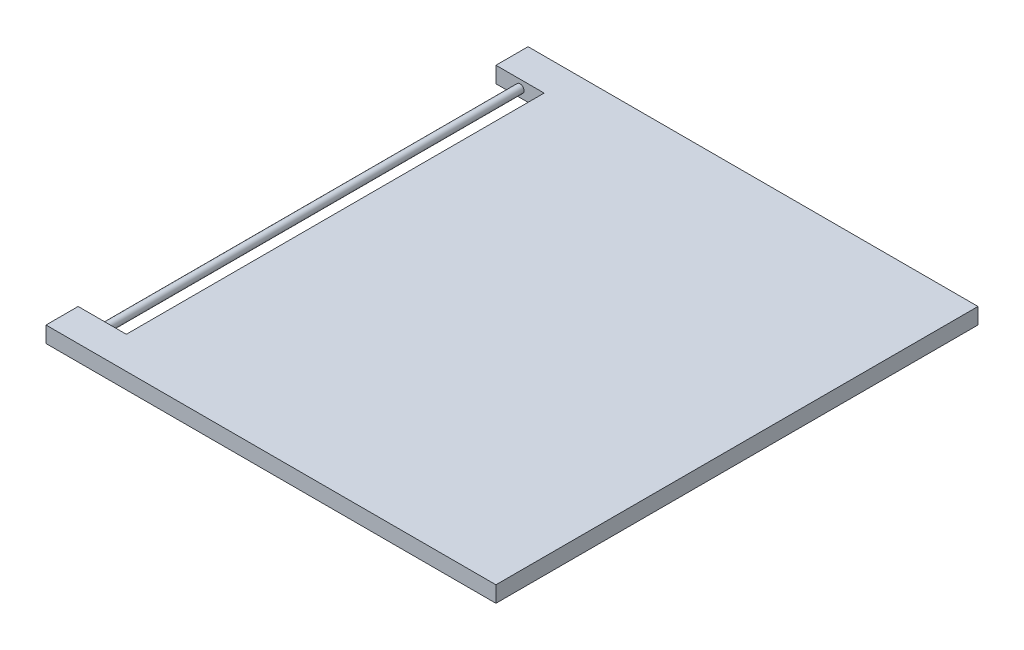
from build123d import *

# Parameters (mm, degrees)
SKETCH1_W           = 250
SKETCH1_H           = 300
BOSS_EXTRUDE1_DEPTH = 10
SKETCH2_W           = 20
SKETCH2_H           = 10
BOSS_EXTRUDE2_DEPTH = 30
SKETCH3_R           = 2.5
BOSS_EXTRUDE3_DEPTH = 260


with BuildPart() as part:
    # Sketch1 → Boss-Extrude1 (new body)
    with BuildSketch(Plane(origin=(0, 0, 0), x_dir=(1, 0, 0), z_dir=(0, 1, 0))):
        with Locations((16.279069767, -63.081395349)):
            Rectangle(SKETCH1_W, SKETCH1_H)
    extrude(amount=BOSS_EXTRUDE1_DEPTH)

    # Sketch2 → Boss-Extrude2 (add)
    with BuildSketch(Plane.ZY.offset(108.720930233)):
        with Locations((-76.918604651, 5)):
            Rectangle(SKETCH2_W, SKETCH2_H)
        with Locations((203.081395349, 5)):
            Rectangle(SKETCH2_W, SKETCH2_H)
    extrude(amount=BOSS_EXTRUDE2_DEPTH)

    # Sketch3 → Boss-Extrude3 (add)
    with BuildSketch(Plane.XY.offset(-66.918604651)):
        with Locations((-123.720930233, 5)):
            Circle(SKETCH3_R)
    extrude(amount=BOSS_EXTRUDE3_DEPTH)


solid = part.part
